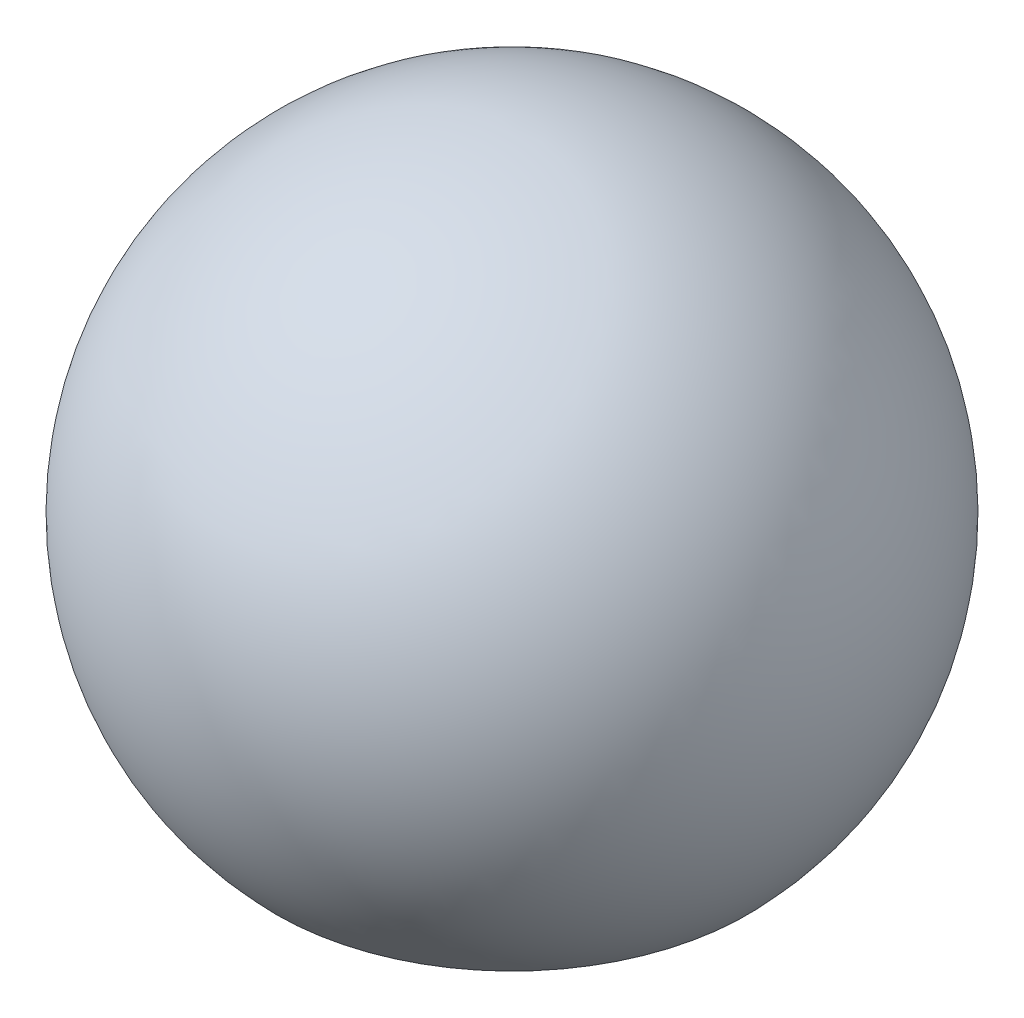
from build123d import *

# Parameters (mm, degrees)
SKETCH2_R          = 0.947350232
CUT_EXTRUDE1_DEPTH = 10
SKETCH3_R          = 6.112646494
CUT_EXTRUDE2_DEPTH = 3


with BuildPart() as part:
    # Sketch1 → Revolve1 (revolve)
    with BuildSketch(Plane(origin=(0, 0, 0), x_dir=(1, 0, 0), z_dir=(0, 1, 0))):
        with BuildLine():
            Line((31.500361685, 88.241279922), (31.500361685, 80.241279922))
            ThreePointArc((31.500361685, 80.241279922), (27.500361685, 84.241279922), (31.500361685, 88.241279922))
        make_face()
    revolve(axis=Axis((31.500361685, 0, -88.241279922), (0, 0, 1)))

    # Sketch2 → Cut-Extrude1 (cut)
    with BuildSketch(Plane(origin=(0, 0, 0), x_dir=(1, 0, 0), z_dir=(0, 1, 0))):
        with Locations((31.500361685, 84.241279922)):
            Circle(SKETCH2_R)
    extrude(amount=-CUT_EXTRUDE1_DEPTH, mode=Mode.SUBTRACT)

    # Sketch3 → Cut-Extrude2 (cut)
    with BuildSketch(Plane(origin=(0, -2.8, 0), x_dir=(-1, 0, 0), z_dir=(0, -1, 0))):
        with Locations((-31.500361685, 84.241279922)):
            Circle(SKETCH3_R)
    extrude(amount=CUT_EXTRUDE2_DEPTH, mode=Mode.SUBTRACT)


solid = part.part
